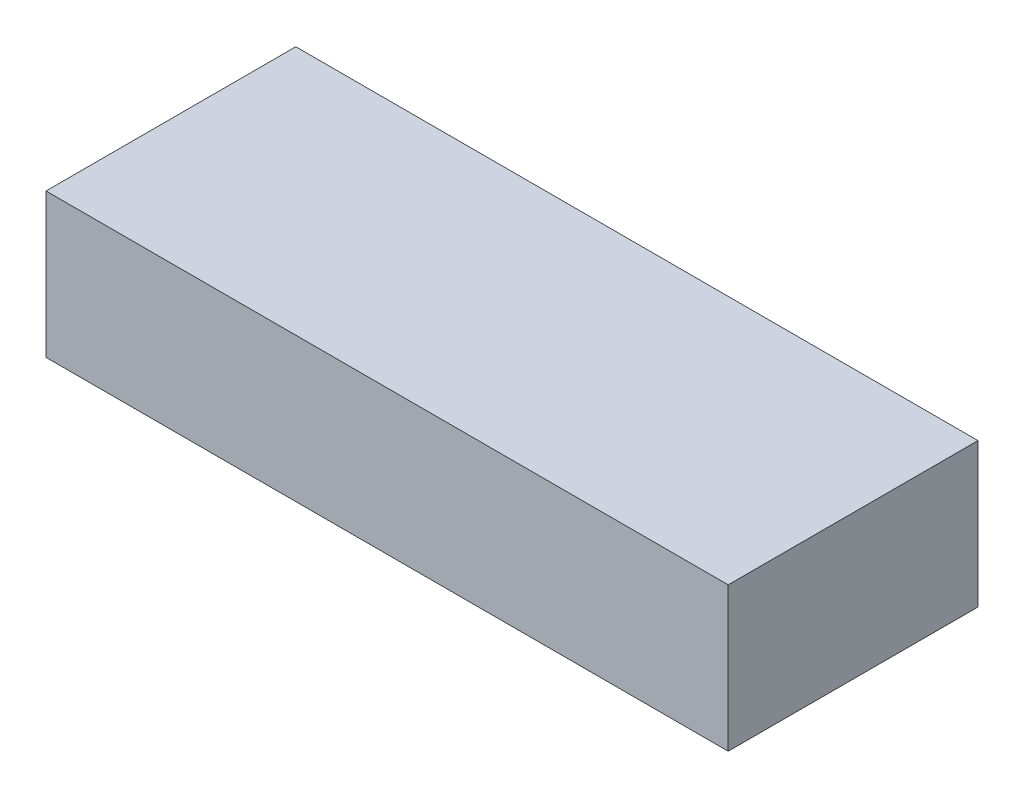
from build123d import *

# Parameters (mm, degrees)
SKETCH1_W           = 142
SKETCH1_H           = 30
BOSS_EXTRUDE1_DEPTH = 52


with BuildPart() as part:
    # Sketch1 → Boss-Extrude1 (new body)
    with BuildSketch(Plane.XY):
        with Locations((-21.782799011, -18.765037594)):
            Rectangle(SKETCH1_W, SKETCH1_H)
    extrude(amount=BOSS_EXTRUDE1_DEPTH)


solid = part.part
